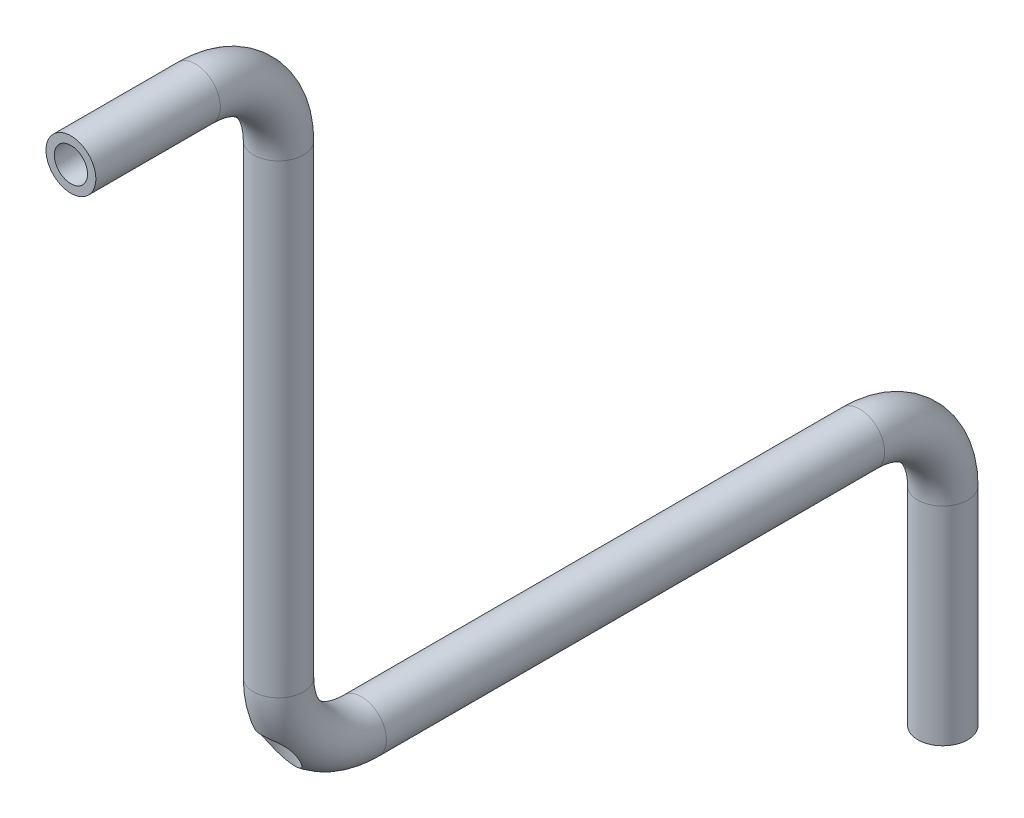
from build123d import *

# Parameters (mm, degrees)
SWEEP_THIN2_PROFILE_R   = 30
SWEEP_THIN2_PROFILE_R_2 = 20
CUT_EXTRUDE1_DEPTH      = 86
CUT_EXTRUDE1_DEPTH_BACK = 10
SKETCH25_R              = 20


with BuildPart() as part:
    # Sweep-Thin2: sweep along a path in Sketch1
    with BuildLine(Plane(origin=(0, 0, 0), x_dir=(0, 0, -1), z_dir=(1, 0, 0))) as sweep_thin2_path:
        Line((800, -350), (800, -100))
        ThreePointArc((800, -100), (770.710678119, -29.289321881), (700, 0))
        Line((700, 0), (100, 0))
        ThreePointArc((100, 0), (29.289321881, 29.289321881), (0, 100))
        Line((0, 100), (0, 660))
        ThreePointArc((0, 660), (-29.289321881, 730.710678119), (-100, 760))
        Line((-100, 760), (-250, 760))
    # Sweep-Thin2 profile (on start of the path) → Sweep-Thin2 (sweep)
    with BuildSketch(Plane(origin=(0, -350, -800), x_dir=(0, 0, 1), z_dir=(0, 1, 0))):
        Circle(SWEEP_THIN2_PROFILE_R)
        Circle(SWEEP_THIN2_PROFILE_R_2, mode=Mode.SUBTRACT)
    sweep(path=sweep_thin2_path.line)

    # Sketch25 → Cut-Extrude1 (cut, two sides: drawn at the far end of the back side and taken through both)
    with BuildSketch(Plane(origin=(0, 0, 0), x_dir=(1, 0, 0), z_dir=(0, 1, 0)).offset(-CUT_EXTRUDE1_DEPTH_BACK)):
        Circle(SKETCH25_R)
    extrude(amount=CUT_EXTRUDE1_DEPTH + CUT_EXTRUDE1_DEPTH_BACK, mode=Mode.SUBTRACT)


solid = part.part
